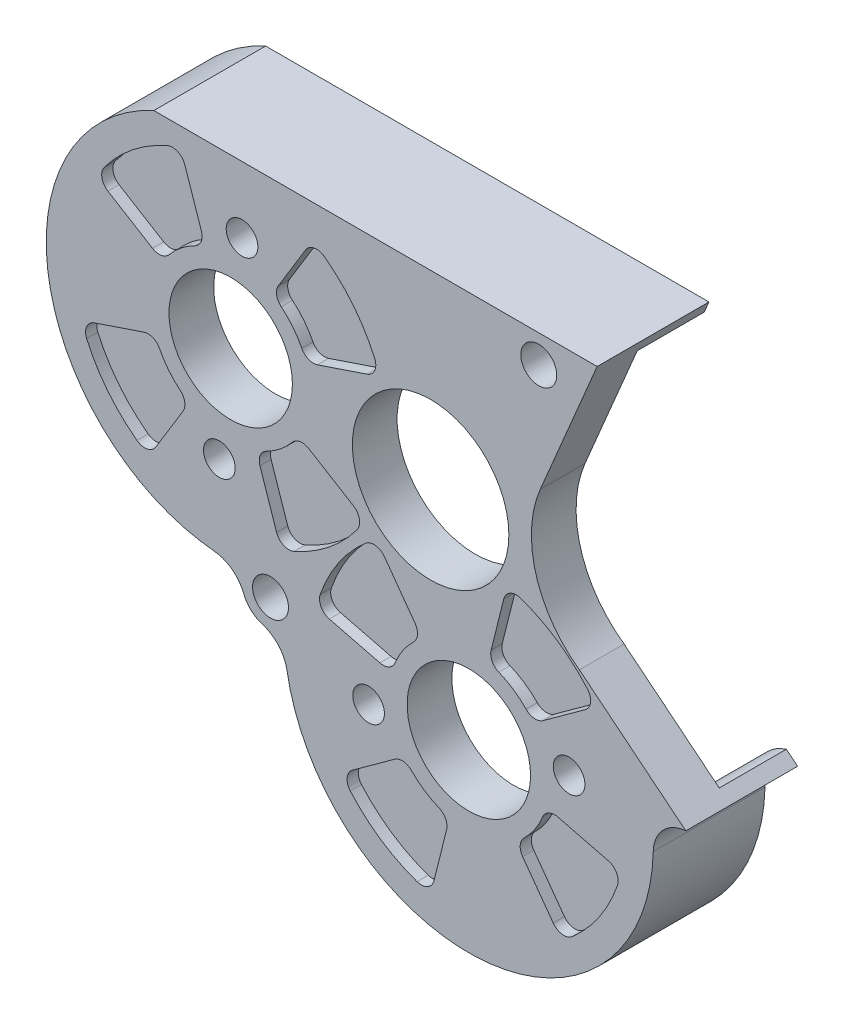
from build123d import *

# Parameters (mm, degrees)
SKETCH1_W                      = 254
SKETCH1_H                      = 127
BOSS_EXTRUDE1_DEPTH            = 6.35
SKETCH3_W                      = 254
SKETCH3_H                      = 127
CUT_EXTRUDE2_DEPTH             = 7.35
BOSS_EXTRUDE2_DEPTH            = 9.525
SKETCH6_R                      = 11.1125
SKETCH6_R_2                    = 8.763
CUT_EXTRUDE4_DEPTH             = 16.875
M4_CLEARANCE_HOLE1_D           = 4.5
F_10_CLEARANCE_HOLE1_D         = 5.1054
CUT_EXTRUDE5_DEPTH             = 1.5875
CUT_EXTRUDE6_DEPTH             = 1.5875
CIRPATTERN1_COUNT              = 4
CUT_EXTRUDE7_DEPTH             = 1.5875
CIRPATTERN2_COUNT              = 4
FILLET1_R                      = 1.8415
FILLET2_R                      = 3.429
SKETCH17_R                     = 3.175
BOSS_EXTRUDE3_DEPTH            = 9.525
F_1_8_0_1250_DOWEL_HOLE1_D     = 3.175
F_1_8_0_1250_DOWEL_HOLE1_DEPTH = 12.0396
F_1_8_0_1250_DOWEL_HOLE1_TIP   = 0.953866233
FILLET3_R                      = 5.0165


with BuildPart() as part:
    # Sketch1 → Boss-Extrude1 (new body)
    with BuildSketch(Plane.XY):
        Rectangle(SKETCH1_W, SKETCH1_H)
    extrude(amount=BOSS_EXTRUDE1_DEPTH)

    # Sketch3 → Cut-Extrude2 (cut, through all)
    with BuildSketch(Plane(origin=(62.029481908, 26.9875, 6.35), x_dir=(-1, 0, 0), z_dir=(0, 0, 1))):
        with Locations((62.029481908, 26.9875)):
            Rectangle(SKETCH3_W, SKETCH3_H)
        with BuildLine():
            Line((38.375704445, 0), (101.339803596, 0))
            ThreePointArc((101.339803596, 0), (116.244041515, 28.242066371), (92.777915064, 49.900587333))
            ThreePointArc((92.777915064, 49.900587333), (90.216951585, 50.884547796), (88.556580176, 53.068553043))
            ThreePointArc((88.556580176, 53.068553043), (87.523970354, 54.577937036), (85.934104742, 55.481734809))
            ThreePointArc((85.934104742, 55.481734809), (83.613147834, 56.962702158), (82.423337364, 59.445534474))
            ThreePointArc((82.423337364, 59.445534474), (54.716755517, 81.168180099), (30.416630865, 55.692074577))
            ThreePointArc((30.416630865, 55.692074577), (29.040002451, 52.362829541), (25.7869078, 50.814813554))
            Line((25.7869078, 50.814813554), (40.905921092, 38.567160383))
            ThreePointArc((40.905921092, 38.567160383), (47.101387217, 29.823563182), (46.450118266, 19.127295548))
            Line((46.450118266, 19.127295548), (38.375704445, 0))
        make_face(mode=Mode.SUBTRACT)
    extrude(amount=-CUT_EXTRUDE2_DEPTH, mode=Mode.SUBTRACT)

    # Sketch5 → Boss-Extrude2 (add)
    with BuildSketch(Plane(origin=(0, 0, 0), x_dir=(-1, 0, 0), z_dir=(0, 0, -1))):
        with BuildLine():
            Line((-23.653777463, 26.9875), (39.310321688, 26.9875))
            ThreePointArc((39.310321688, 26.9875), (54.214559607, -1.254566371), (30.748433156, -22.913087333))
            ThreePointArc((30.748433156, -22.913087333), (28.187469677, -23.897047796), (26.527098268, -26.081053043))
            ThreePointArc((26.527098268, -26.081053043), (25.494488447, -27.590437036), (23.904622834, -28.494234809))
            ThreePointArc((23.904622834, -28.494234809), (21.583665926, -29.975202158), (20.393855456, -32.458034474))
            ThreePointArc((20.393855456, -32.458034474), (-7.312726391, -54.180680099), (-31.612851042, -28.704574577))
            ThreePointArc((-31.612851042, -28.704574577), (-32.989479457, -25.375329541), (-36.242574108, -23.827313554))
            Line((-36.242574108, -23.827313554), (-34.641929347, -22.530658706))
            ThreePointArc((-34.641929347, -22.530658706), (-31.350883895, -24.858245557), (-30.025839433, -28.665199443))
            ThreePointArc((-30.025839433, -28.665199443), (-7.198449609, -52.59729857), (18.82894546, -32.191176922))
            ThreePointArc((18.82894546, -32.191176922), (20.39527823, -28.922638177), (23.450715172, -26.973010274))
            ThreePointArc((23.450715172, -26.973010274), (24.41953953, -26.422258506), (25.04878614, -25.502477636))
            ThreePointArc((25.04878614, -25.502477636), (27.234591539, -22.627331487), (30.605986499, -21.331991131))
            ThreePointArc((30.605986499, -21.331991131), (52.620485078, -1.154182712), (38.958220229, 25.4))
            Line((38.958220229, 25.4), (-22.983628779, 25.4))
            Line((-22.983628779, 25.4), (-23.653777463, 26.9875))
        make_face()
    extrude(amount=BOSS_EXTRUDE2_DEPTH)

    # Sketch6 → Cut-Extrude4 (cut, through all)
    with BuildSketch(Plane(origin=(62.029481908, 26.9875, 6.35), x_dir=(-1, 0, 0), z_dir=(0, 0, 1))):
        with Locations(Location((62.029481908, 26.9875, 0), (0, 0, 180))):  # turned: the seam where the file's is
            Circle(SKETCH6_R)
        with Locations(Location((90.427545222, 23.8125, 0), (0, 0, 180))):  # turned: the seam where the file's is
            Circle(SKETCH6_R_2)
        with Locations(Location((56.602322423, 55.042384867, 0), (0, 0, 180))):  # turned: the seam where the file's is
            Circle(SKETCH6_R_2)
    extrude(amount=-CUT_EXTRUDE4_DEPTH, mode=Mode.SUBTRACT)

    # M4 Clearance Hole1 (through all)
    with Locations(Plane(origin=(0, 0, 0), x_dir=(-1, 0, 0), z_dir=(0, 0, -1))):
        with Locations((-19.663234046, -25.300945671), (26.786952203, 17.585215855), (30.009174425, -11.235215855), (8.808915076, -30.808824064)):
            Hole(M4_CLEARANCE_HOLE1_D / 2)

    # 10 Clearance Hole1 (through all)
    with Locations(Plane(origin=(62.029481908, 26.9875, 6.35), x_dir=(-1, 0, 0), z_dir=(0, 0, 1))):
        with Locations((84.772101128, 51.5874), (46.672101128, 3.9624)):
            Hole(F_10_CLEARANCE_HOLE1_D / 2)

    # Sketch11 → Cut-Extrude5 (cut)
    with BuildSketch(Plane(origin=(62.029481908, 26.9875, 6.35), x_dir=(-1, 0, 0), z_dir=(0, 0, 1))):
        with BuildLine():
            Line((65.750179158, 61.676140753), (69.555039924, 64.435313555))
            ThreePointArc((69.555039924, 64.435313555), (65.561324662, 68.298940939), (60.487021509, 70.563632015))
            Line((60.487021509, 70.563632015), (59.345891152, 66.004265665))
            ThreePointArc((59.345891152, 66.004265665), (62.929617754, 64.404827593), (65.750179158, 61.676140753))
        make_face()
        with BuildLine():
            Line((63.236078309, 45.894528132), (65.995251111, 42.089667366))
            ThreePointArc((65.995251111, 42.089667366), (69.858878495, 46.083382629), (72.12356957, 51.157685782))
            Line((72.12356957, 51.157685782), (67.564203221, 52.298816138))
            ThreePointArc((67.564203221, 52.298816138), (65.964765149, 48.715089536), (63.236078309, 45.894528132))
        make_face()
        with BuildLine():
            Line((76.767731854, 32.143736327), (80.780302031, 29.696435656))
            ThreePointArc((80.780302031, 29.696435656), (83.374526501, 32.641142416), (86.81944912, 34.520984604))
            Line((86.81944912, 34.520984604), (85.318736582, 38.974956077))
            ThreePointArc((85.318736582, 38.974956077), (80.440970042, 36.313232625), (76.767731854, 32.143736327))
        make_face()
        with BuildLine():
            Line((79.719060618, 20.204403898), (75.265089145, 18.70369136))
            ThreePointArc((75.265089145, 18.70369136), (77.926812597, 13.825924819), (82.096308895, 10.152686632))
            Line((82.096308895, 10.152686632), (84.543609566, 14.165256809))
            ThreePointArc((84.543609566, 14.165256809), (81.598902806, 16.759481279), (79.719060618, 20.204403898))
        make_face()
        with BuildLine():
            Line((94.035641324, 13.104015396), (95.536353862, 8.650043923))
            ThreePointArc((95.536353862, 8.650043923), (100.414120403, 11.311767375), (104.08735859, 15.481263672))
            Line((104.08735859, 15.481263672), (100.074788414, 17.928564344))
            ThreePointArc((100.074788414, 17.928564344), (97.480563944, 14.983857583), (94.035641324, 13.104015396))
        make_face()
        with BuildLine():
            Line((101.136029826, 27.420596102), (105.590001299, 28.92130864))
            ThreePointArc((105.590001299, 28.92130864), (102.928277847, 33.799075181), (98.75878155, 37.472313368))
            Line((98.75878155, 37.472313368), (96.311480878, 33.459743191))
            ThreePointArc((96.311480878, 33.459743191), (99.256187639, 30.865518721), (101.136029826, 27.420596102))
        make_face()
        with BuildLine():
            Line((49.968566537, 64.190241603), (47.209393735, 67.995102368))
            ThreePointArc((47.209393735, 67.995102368), (43.345766351, 64.001387106), (41.081075275, 58.927083953))
            Line((41.081075275, 58.927083953), (45.640441625, 57.785953597))
            ThreePointArc((45.640441625, 57.785953597), (47.239879697, 61.369680199), (49.968566537, 64.190241603))
        make_face()
        with BuildLine():
            Line((47.454465688, 48.408628982), (43.649604922, 45.649456179))
            ThreePointArc((43.649604922, 45.649456179), (47.643320184, 41.785828796), (52.717623337, 39.52113772))
            Line((52.717623337, 39.52113772), (53.858753694, 44.08050407))
            ThreePointArc((53.858753694, 44.08050407), (50.275027092, 45.679942142), (47.454465688, 48.408628982))
        make_face()
    extrude(amount=-CUT_EXTRUDE5_DEPTH, mode=Mode.SUBTRACT)

    # Sketch12 → Cut-Extrude6 (cut)
    with BuildSketch(Plane.XY.offset(6.35)):
        with BuildLine():
            Line((-42.057876682, 11.506236328), (-47.479115113, 14.812695745))
            ThreePointArc((-47.479115113, 14.812695745), (-42.34806052, 20.636960886), (-35.534430383, 24.355055832))
            Line((-35.534430383, 24.355055832), (-33.506871954, 18.337456077))
            ThreePointArc((-33.506871954, 18.337456077), (-38.384638495, 15.675732625), (-42.057876682, 11.506236328))
        make_face()
    cut_extrude6 = extrude(amount=-CUT_EXTRUDE6_DEPTH, mode=Mode.SUBTRACT)

    # CirPattern1: Cut-Extrude6 ×4 about axis
    cirpattern1_axis = Axis((-28.398063314, 3.175, -9.525), (0, 0, 1))
    for i in range(1, CIRPATTERN1_COUNT):
        add(cut_extrude6.rotate(cirpattern1_axis, i * 360 / CIRPATTERN1_COUNT), mode=Mode.SUBTRACT)

    # Sketch13 → Cut-Extrude7 (cut)
    with BuildSketch(Plane.XY.offset(6.35)):
        with BuildLine():
            Line((-10.094087663, -24.170185782), (-16.254082624, -22.628445832))
            ThreePointArc((-16.254082624, -22.628445832), (-13.090592278, -15.540278615), (-7.693587776, -9.961557608))
            Line((-7.693587776, -9.961557608), (-3.965769203, -15.102167366))
            ThreePointArc((-3.965769203, -15.102167366), (-7.829396587, -19.095882629), (-10.094087663, -24.170185782))
        make_face()
    cut_extrude7 = extrude(amount=-CUT_EXTRUDE7_DEPTH, mode=Mode.SUBTRACT)

    # CirPattern2: Cut-Extrude7 ×4 about axis
    cirpattern2_axis = Axis((5.427159485, -28.054884867, -9.525), (0, 0, 1))
    for i in range(1, CIRPATTERN2_COUNT):
        add(cut_extrude7.rotate(cirpattern2_axis, i * 360 / CIRPATTERN2_COUNT), mode=Mode.SUBTRACT)

    # Fillet1
    fillet1_edges = [part.edges().sort_by_distance(p)[0] for p in [
        (-3.72069725, -34.688640753, 5.55625),
        (2.683590756, -39.016765665, 5.55625),
        (12.060915371, -37.202741603, 5.55625),
        (16.389040283, -30.798453597, 5.55625),
        (14.57501622, -21.421128982, 5.55625),
        (8.170728214, -17.09300407, 5.55625),
        (-32.006159416, 13.883484604, 5.55625),
        (-38.045306506, 9.058935656, 5.55625),
        (-39.106547918, -0.433096102, 5.55625),
        (-34.281998971, -6.472243191, 5.55625),
        (-17.68957871, 6.783096102, 5.55625),
        (-22.514127658, 12.822243191, 5.55625),
        (-24.789967212, -7.533484604, 5.55625),
        (-18.750820123, -2.708935656, 5.55625),
        (-1.206596401, -18.907028132, 5.55625),
        (-5.534721313, -25.311316138, 5.55625),
        (-47.479115113, 14.812695745, 5.55625),
        (-35.534430383, 24.355055832, 5.55625),
        (-40.035759059, -15.906051799, 5.55625),
        (-49.578119146, -3.961367069, 5.55625),
        (-9.317011515, -8.462695745, 5.55625),
        (-21.261696245, -18.005055832, 5.55625),
        (-16.760367569, 22.256051799, 5.55625),
        (-7.218007482, 10.311367069, 5.55625),
        (-16.254082624, -22.628445832, 5.55625),
        (-7.693587776, -9.961557608, 5.55625),
        (0.00072045, -49.736126977, 5.55625),
        (-12.666167774, -41.175632128, 5.55625),
        (27.108401594, -33.481323903, 5.55625),
        (18.547906746, -46.148212127, 5.55625),
        (10.85359852, -6.373642758, 5.55625),
        (23.520486744, -14.934137606, 5.55625),
    ]]
    fillet(fillet1_edges, radius=FILLET1_R)

    # Fillet2
    fillet2_edges = [part.edges().sort_by_distance(p)[0] for p in [
        (-38.958220229, 25.4, -4.7625),
    ]]
    fillet(fillet2_edges, radius=FILLET2_R)

    # Sketch17 → Boss-Extrude3 (add)
    with BuildSketch(Plane(origin=(0, 0, 0), x_dir=(-1, 0, 0), z_dir=(0, 0, -1))):
        with Locations((-5.427159485, -51.073634867)):
            Circle(SKETCH17_R)
        with Locations((51.416813314, 3.175)):
            Circle(SKETCH17_R)
    extrude(amount=BOSS_EXTRUDE3_DEPTH)

    # 1_8 _0.1250_ Dowel Hole1
    with Locations(Plane(origin=(0, 0, -9.525), x_dir=(-1, 0, 0), z_dir=(0, 0, -1))):
        with Locations((-5.427159485, -51.073634867), (51.416813314, 3.175)):
            Hole(F_1_8_0_1250_DOWEL_HOLE1_D / 2, depth=F_1_8_0_1250_DOWEL_HOLE1_DEPTH)
            with Locations((0, 0, -(F_1_8_0_1250_DOWEL_HOLE1_DEPTH + F_1_8_0_1250_DOWEL_HOLE1_TIP / 2))):  # 118° drill point
                Cone(0, F_1_8_0_1250_DOWEL_HOLE1_D / 2, F_1_8_0_1250_DOWEL_HOLE1_TIP, mode=Mode.SUBTRACT)

    # Fillet3
    fillet3_edges = [part.edges().sort_by_distance(p)[0] for p in [
        (2.589042007, -52.496910729, -4.7625),
        (8.265276963, -52.496910729, -4.7625),
        (-52.840089176, 6.013117478, -4.7625),
        (-52.840089176, 0.336882522, -4.7625),
    ]]
    fillet(fillet3_edges, radius=FILLET3_R)


solid = part.part
